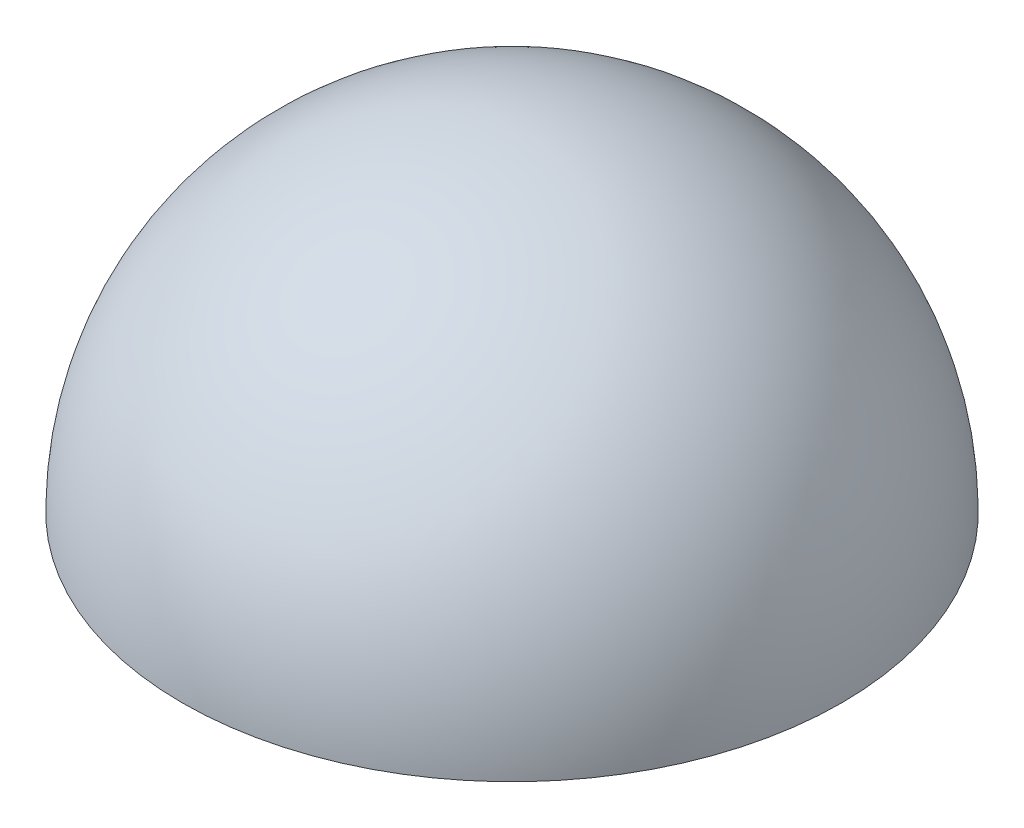
from build123d import *


with BuildPart() as part:
    # Sketch1 → Revolve1 (revolve)
    with BuildSketch(Plane.XY):
        with BuildLine():
            Line((0, 20), (0, 0))
            Line((0, 0), (20, 0))
            ThreePointArc((20, 0), (14.142135624, 14.142135624), (0, 20))
        make_face()
    revolve(axis=Axis((0, 20, 0), (0, -1, 0)))


solid = part.part
